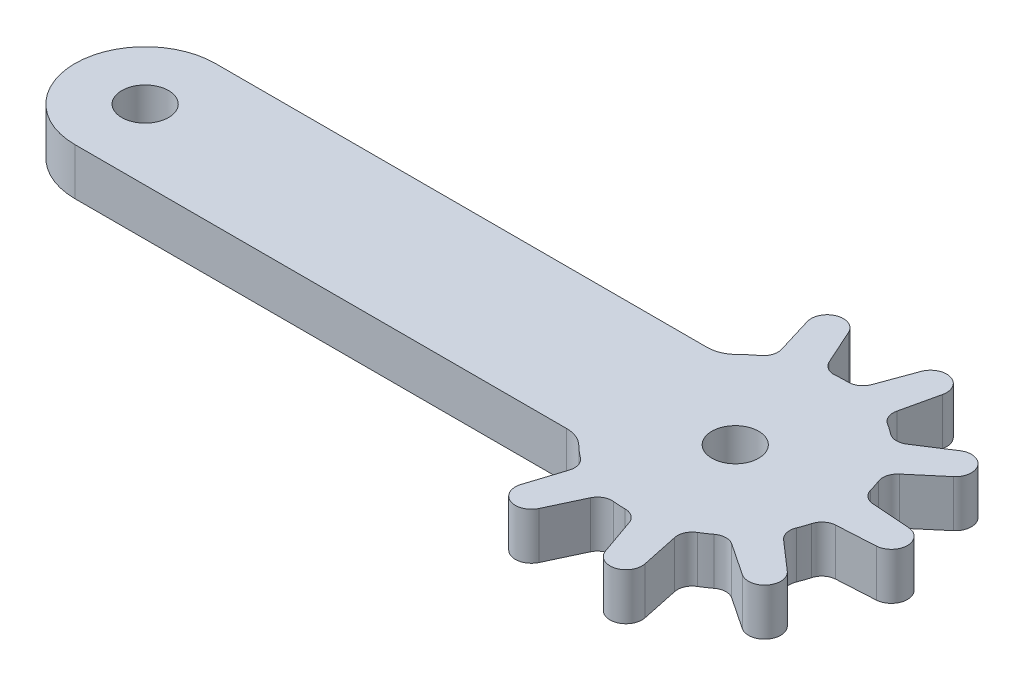
from build123d import *

# Parameters (mm, degrees)
CROQUIS1_R              = 1.5875
SALIENTE_EXTRUIR1_DEPTH = 3.175
CROQUIS2_R              = 7.5
CROQUIS2_R_2            = 1.5875
SALIENTE_EXTRUIR2_DEPTH = 3.175
SALIENTE_EXTRUIR3_DEPTH = 3.175
CORTAR_EXTRUIR1_DEPTH   = 10
REDONDEO3_R             = 1
MATRIZC2_COUNT          = 7
MATRIZC2_ANGLE          = 222
REDONDEO3_OF_MATRIZC2_R = 1
REDONDEO4_R             = 2


with BuildPart() as part:
    # Croquis1 → Saliente-Extruir1 (new body)
    with BuildSketch(Plane(origin=(0, 0, 0), x_dir=(1, 0, 0), z_dir=(0, 1, 0))):
        with BuildLine():
            Line((-20, 0), (20, 0))
            ThreePointArc((20, 0), (24.7625, -4.7625), (20, -9.525))
            Line((20, -9.525), (-20, -9.525))
            ThreePointArc((-20, -9.525), (-24.7625, -4.7625), (-20, 0))
        make_face()
        with Locations((-20, -4.7625)):
            Circle(CROQUIS1_R, mode=Mode.SUBTRACT)
        with Locations((20, -4.7625)):
            Circle(CROQUIS1_R, mode=Mode.SUBTRACT)
    extrude(amount=SALIENTE_EXTRUIR1_DEPTH)

    # Croquis2 → Saliente-Extruir2 (add)
    with BuildSketch(Plane(origin=(0, 3.175, 0), x_dir=(1, 0, 0), z_dir=(0, 1, 0))):
        with Locations((20, -4.7625)):
            Circle(CROQUIS2_R)
        with Locations((20, -4.7625)):
            Circle(CROQUIS2_R_2, mode=Mode.SUBTRACT)
    extrude(amount=-SALIENTE_EXTRUIR2_DEPTH)

    # Croquis8 → Saliente-Extruir3 (add)
    with BuildSketch(Plane(origin=(0, 3.175, 0), x_dir=(1, 0, 0), z_dir=(0, 1, 0))):
        with BuildLine():
            Line((14.926688775, 5.835802374), (16.184441281, 1.694396442))
            ThreePointArc((16.184441281, 1.694396442), (17.363636492, 2.258866495), (18.622936274, 2.60999588))
            Line((18.622936274, 2.60999588), (16.844139666, 6.555761596))
            ThreePointArc((16.844139666, 6.555761596), (15.869697171, 6.237640842), (14.926688775, 5.835802374))
        make_face()
    saliente_extruir3 = extrude(amount=-SALIENTE_EXTRUIR3_DEPTH)

    # Croquis9 → Cortar-Extruir1 (cut)
    with BuildSketch(Plane(origin=(0, 3.175, 0), x_dir=(1, 0, 0), z_dir=(0, 1, 0))):
        with BuildLine():
            ThreePointArc((16.844139666, 6.555761596), (16.353447772, 6.407332445), (15.869697296, 6.237640889))
            ThreePointArc((15.869697296, 6.237640889), (16.670669085, 6.223682337), (17.245417982, 5.665637219))
            Line((17.245417982, 5.665637219), (16.844139666, 6.555761596))
        make_face()
        with BuildLine():
            ThreePointArc((15.869697296, 6.237640889), (15.393808961, 6.047009892), (14.926688775, 5.835802374))
            Line((14.926688775, 5.835802374), (15.210424872, 4.901543567))
            ThreePointArc((15.210424872, 4.901543567), (15.275853116, 5.699960746), (15.869697296, 6.237640889))
        make_face()
    cortar_extruir1 = extrude(amount=-CORTAR_EXTRUIR1_DEPTH, mode=Mode.SUBTRACT)

    # Redondeo3
    redondeo3_edges = [part.edges().sort_by_distance(p)[0] for p in [
        (18.622936274, 1.5875, -2.60999588),
        (16.184441281, 1.5875, -1.694396442),
    ]]
    fillet(redondeo3_edges, radius=REDONDEO3_R)

    # MatrizC2: Saliente-Extruir3, Cortar-Extruir1 ×7 about axis
    matrizc2_axis = Axis((20, 0, 4.7625), (0, -1, 0))
    for i in range(1, MATRIZC2_COUNT):
        add(saliente_extruir3.rotate(matrizc2_axis, i * MATRIZC2_ANGLE / (MATRIZC2_COUNT - 1)))
        add(cortar_extruir1.rotate(matrizc2_axis, i * MATRIZC2_ANGLE / (MATRIZC2_COUNT - 1)), mode=Mode.SUBTRACT)

    # Redondeo3 of MatrizC2
    redondeo3_of_matrizc2_edges = [part.edges().sort_by_distance(p)[0] for p in [
        (23.337106788, 1.5875, -1.954174645),
        (20.838616598, 1.5875, -2.690467342),
        (26.707327688, 1.5875, 1.406646118),
        (25.155056708, 1.5875, -0.685012307),
        (27.376313351, 1.5875, 6.118966491),
        (27.395406089, 1.5875, 3.514313802),
        (25.074643863, 1.5875, 10.284998498),
        (26.657411119, 1.5875, 8.216320666),
        (20.729268228, 1.5875, 12.226960319),
        (23.238283761, 1.5875, 11.527373856),
        (16.090195144, 1.5875, 11.16276765),
        (18.515005687, 1.5875, 12.114016299),
    ]]
    fillet(redondeo3_of_matrizc2_edges, radius=REDONDEO3_OF_MATRIZC2_R)

    # Redondeo4
    redondeo4_edges = [part.edges().sort_by_distance(p)[0] for p in [
        (14.206158981, 1.5875, 0),
        (14.206158981, 1.5875, 9.525),
    ]]
    fillet(redondeo4_edges, radius=REDONDEO4_R)


solid = part.part
